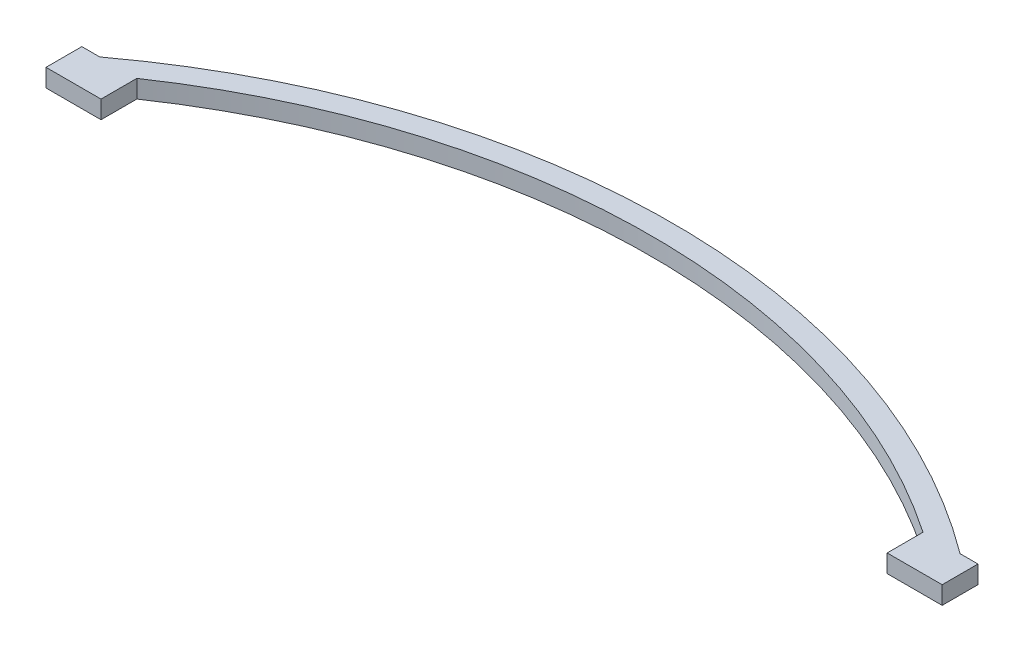
from build123d import *

# Parameters (mm, degrees)
BOSS_EXTRUDE2_DEPTH = 3.175
SKETCH2_W           = 9.745232509
SKETCH2_H           = 3.175
BOSS_EXTRUDE3_DEPTH = 6.35


with BuildPart() as part:
    # Sketch1 → Boss-Extrude2 (new body)
    with BuildSketch(Plane(origin=(0, 0, 0), x_dir=(1, 0, 0), z_dir=(0, 1, 0))):
        with BuildLine():
            Line((-76.2, 0), (-69.629767491, 0))
            ThreePointArc((-69.629767491, 0), (0, 21.43), (69.629767491, 0))
            Line((69.629767491, 0), (76.2, 0))
            ThreePointArc((76.2, 0), (0, 25.24), (-76.2, 0))
        make_face()
    extrude(amount=BOSS_EXTRUDE2_DEPTH)

    # Sketch2 → Boss-Extrude3 (add)
    with BuildSketch(Plane.XY):
        with Locations((-74.502383745, 1.5875)):
            Rectangle(SKETCH2_W, SKETCH2_H)
        with Locations((74.502383745, 1.5875)):
            Rectangle(SKETCH2_W, SKETCH2_H)
    extrude(amount=BOSS_EXTRUDE3_DEPTH)


solid = part.part
